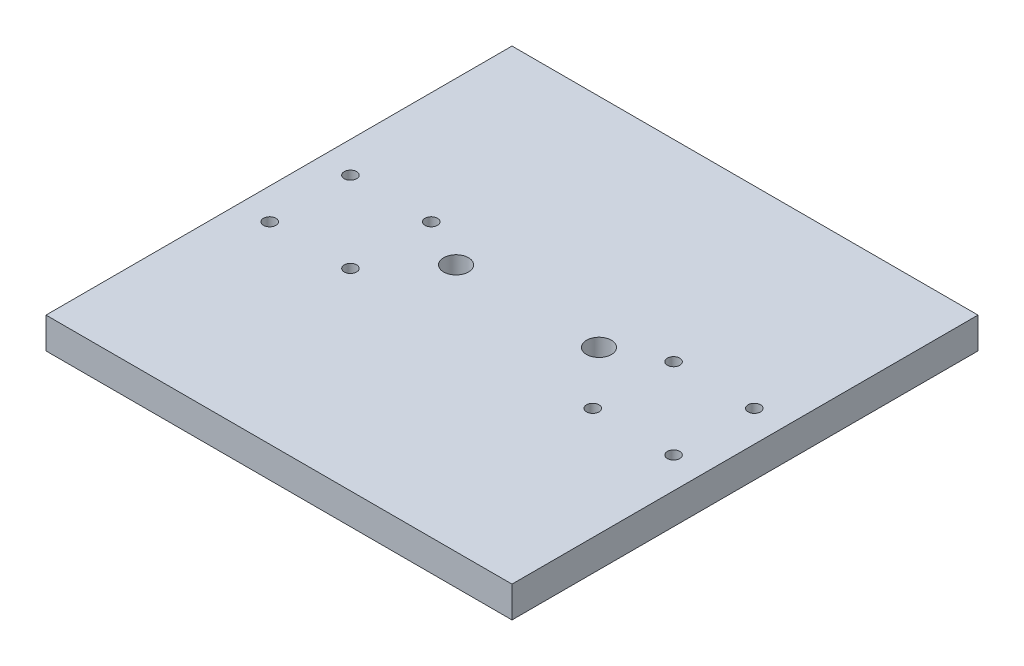
from build123d import *

# Parameters (mm, degrees)
SKETCH1_W           = 150
SKETCH1_H           = 150
BOSS_EXTRUDE1_DEPTH = 10
SKETCH2_R           = 4
SKETCH2_R_2         = 2
CUT_EXTRUDE1_DEPTH  = 10


with BuildPart() as part:
    # Sketch1 → Boss-Extrude1 (new body)
    with BuildSketch(Plane(origin=(0, 0, 0), x_dir=(1, 0, 0), z_dir=(0, 1, 0))):
        Rectangle(SKETCH1_W, SKETCH1_H)
    extrude(amount=BOSS_EXTRUDE1_DEPTH)

    # Sketch2 → Cut-Extrude1 (cut)
    with BuildSketch(Plane(origin=(0, 10, 0), x_dir=(1, 0, 0), z_dir=(0, 1, 0))):
        with Locations((23, 5)):
            Circle(SKETCH2_R)
        with Locations((-23, 5)):
            Circle(SKETCH2_R)
        with Locations((-65, 13)):
            Circle(SKETCH2_R_2)
        with Locations((-39, 13)):
            Circle(SKETCH2_R_2)
        with Locations((-65, -13)):
            Circle(SKETCH2_R_2)
        with Locations((-39, -13)):
            Circle(SKETCH2_R_2)
        with Locations((39, 13)):
            Circle(SKETCH2_R_2)
        with Locations((65, 13)):
            Circle(SKETCH2_R_2)
        with Locations((65, -13)):
            Circle(SKETCH2_R_2)
        with Locations((39, -13)):
            Circle(SKETCH2_R_2)
    extrude(amount=-CUT_EXTRUDE1_DEPTH, mode=Mode.SUBTRACT)


solid = part.part
